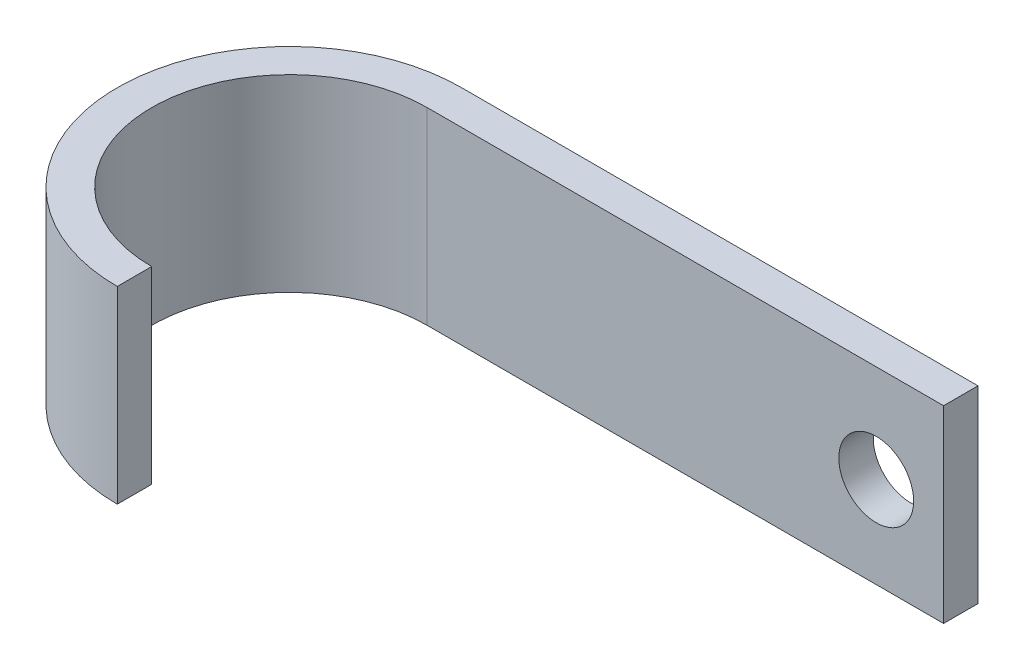
from build123d import *

# Parameters (mm, degrees)
BOSS_EXTRUDE1_DEPTH = 12.6
SKETCH2_R           = 2.5
CUT_EXTRUDE1_DEPTH  = 12.6


with BuildPart() as part:
    # Sketch1 → Boss-Extrude1 (new body)
    with BuildSketch(Plane(origin=(0, 0, 0), x_dir=(1, 0, 0), z_dir=(0, 1, 0))):
        with BuildLine():
            Line((0, 11.5), (11.5, 11.5))
            Line((11.5, 11.5), (34.5, 11.5))
            Line((34.5, 11.5), (34.5, 9.2))
            Line((34.5, 9.2), (0, 9.2))
            ThreePointArc((0, 9.2), (-9.2, 0), (0, -9.2))
            Line((0, -9.2), (0, -11.5))
            ThreePointArc((0, -11.5), (-11.5, 0), (0, 11.5))
        make_face()
    extrude(amount=BOSS_EXTRUDE1_DEPTH)

    # Sketch2 → Cut-Extrude1 (cut)
    with BuildSketch(Plane.XY.offset(-9.2)):
        with Locations((30, 6.079989629)):
            Circle(SKETCH2_R)
    extrude(amount=-CUT_EXTRUDE1_DEPTH, mode=Mode.SUBTRACT)


solid = part.part
